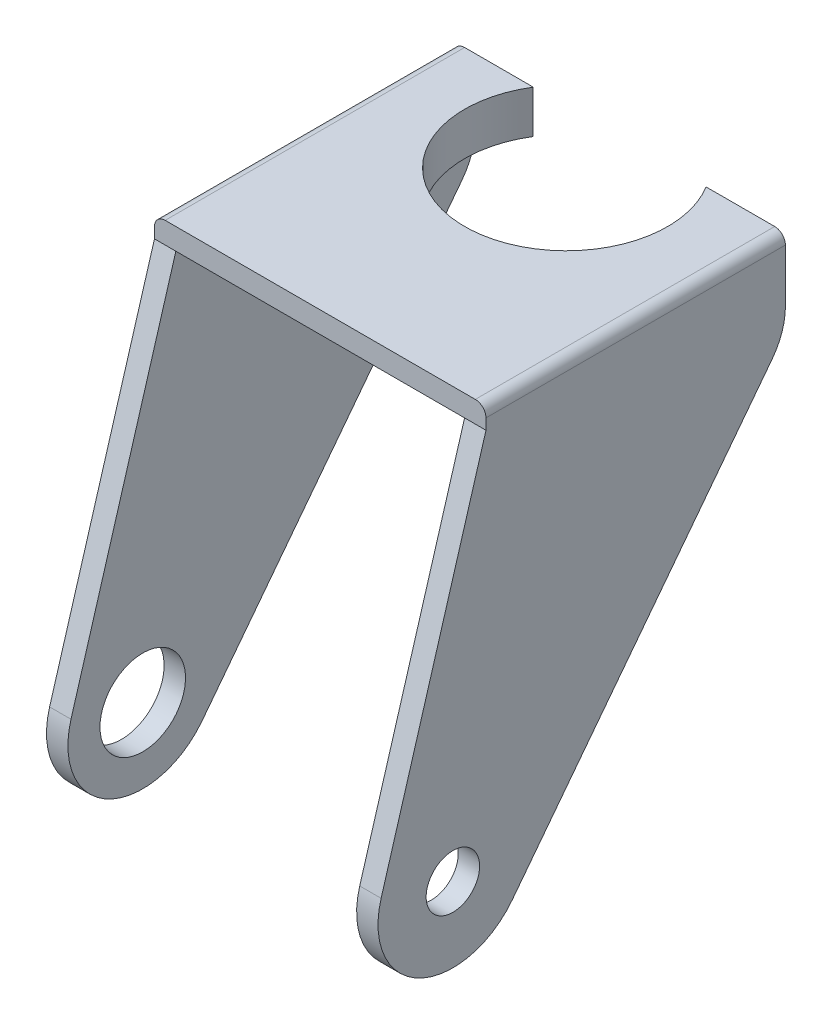
from build123d import *
from build123d.topology import SkipClean

# Parameters (mm, degrees)
BOSS_EXTRUDE1_DEPTH = 2
SKETCH2_W           = 31
SKETCH2_H           = 28
BOSS_EXTRUDE2_DEPTH = 2
BOSS_EXTRUDE3_DEPTH = 4
CUT_EXTRUDE1_DEPTH  = 4
FILLET1_R           = 1
CUT_EXTRUDE2_START  = -29
SKETCH5_R           = 4
CUT_EXTRUDE2_DEPTH  = 10
SKETCH6_R           = 2.5
CUT_EXTRUDE3_DEPTH  = 10
SCALE1_SCALE        = 0.5


with BuildPart() as part:
    # Sketch1 → Boss-Extrude1 (new body)
    with BuildSketch(Plane(origin=(0, 0, 0), x_dir=(0, 0, -1), z_dir=(1, 0, 0))):
        with BuildLine():
            Line((-6.709990017, 1.993999493), (3.096579457, 34.993999493))
            Line((3.096579457, 34.993999493), (3.096579457, 36.993999493))
            Line((3.096579457, 36.993999493), (31.096579457, 36.993999493))
            Line((31.096579457, 36.993999493), (31.096579457, 31.032332545))
            ThreePointArc((31.096579457, 31.032332545), (30.777696783, 29.102331009), (29.854944147, 27.377477489))
            Line((29.854944147, 27.377477489), (5.551425471, -4.263997566))
            ThreePointArc((5.551425471, -4.263997566), (-3.182169032, -6.234885745), (-6.709990017, 1.993999493))
        make_face()
    extrude(amount=-BOSS_EXTRUDE1_DEPTH)


with BuildPart() as body_2:
    # Mirror1: mirrored copy
    add(part.part.mirror(Plane(origin=(-15.5, 0, 0), x_dir=(0, 0, 1), z_dir=(1, 0, 0))))


with BuildPart() as part_1:
    add(part.part)

    add(body_2.part)  # Boss-Extrude2 merges body 2
    # Sketch2 → Boss-Extrude2 (add)
    with BuildSketch(Plane(origin=(0, 36.993999493, 0), x_dir=(1, 0, 0), z_dir=(0, 1, 0))):
        with Locations((-15.5, 17.096579457)):
            Rectangle(SKETCH2_W, SKETCH2_H)
    extrude(amount=-BOSS_EXTRUDE2_DEPTH)

    # Sketch3 → Boss-Extrude3 (add)
    with BuildSketch(Plane(origin=(0, 36.993999493, 0), x_dir=(1, 0, 0), z_dir=(0, 1, 0))):
        with BuildLine():
            Line((-7.41958555, 31.09226783), (-5.143842411, 31.096579457))
            ThreePointArc((-5.143842411, 31.096579457), (-15.5, 14.596579457), (-25.856157589, 31.096579457))
            Line((-25.856157589, 31.096579457), (-23.58041445, 31.09226783))
            ThreePointArc((-23.58041445, 31.09226783), (-15.5, 16.596579457), (-7.41958555, 31.09226783))
        make_face()
    extrude(amount=-BOSS_EXTRUDE3_DEPTH)

    # Sketch4 → Cut-Extrude1 (cut)
    with SkipClean():  # the faces are left unmerged after this step: merging them gives an invalid solid
        with BuildSketch(Plane.XZ.offset(-34.993999493)):
            with BuildLine():
                Line((-5.143842411, -31.096579457), (-7.41958555, -31.09226783))
                ThreePointArc((-7.41958555, -31.09226783), (-15.5, -16.596579457), (-23.58041445, -31.09226783))
                Line((-23.58041445, -31.09226783), (-25.856157589, -31.096579457))
                Line((-25.856157589, -31.096579457), (-5.143842411, -31.096579457))
            make_face()
        extrude(amount=-CUT_EXTRUDE1_DEPTH, mode=Mode.SUBTRACT)

    # Fillet1
    fillet1_edges = [part_1.edges().sort_by_distance(p)[0] for p in [
        (-31, 36.993999493, -17.096579457),
        (0, 36.993999493, -17.096579457),
    ]]
    fillet(fillet1_edges, radius=FILLET1_R)

    # Sketch5 → Cut-Extrude2 (cut)
    with SkipClean():  # the faces are left unmerged after this step: merging them gives an invalid solid
        with BuildSketch(Plane(origin=(0, 0, 0), x_dir=(0, 0, -1), z_dir=(1, 0, 0)).offset(CUT_EXTRUDE2_START)):
            with Locations(Location((0, 0, 0), (0, 0, 180))):
                Circle(SKETCH5_R)
        extrude(amount=-CUT_EXTRUDE2_DEPTH, mode=Mode.SUBTRACT)

    # Sketch6 → Cut-Extrude3 (cut)
    with SkipClean():  # the faces are left unmerged after this step: merging them gives an invalid solid
        with BuildSketch(Plane(origin=(0, 0, 0), x_dir=(0, 0, -1), z_dir=(1, 0, 0))):
            Circle(SKETCH6_R)
        extrude(amount=-CUT_EXTRUDE3_DEPTH, mode=Mode.SUBTRACT)


with BuildPart() as part_2:
    # Scale1: scaled about (0, 0, 0)
    add(part_1.part.scale(SCALE1_SCALE))


solid = part_2.part
